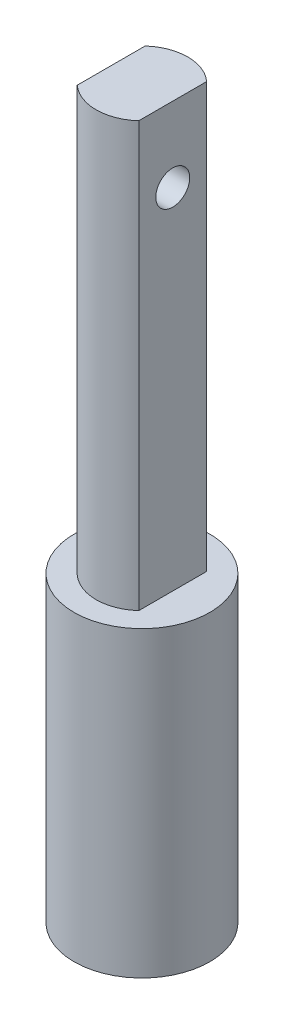
from build123d import *

# Parameters (mm, degrees)
SKETCH1_R           = 4
BOSS_EXTRUDE1_DEPTH = 9
SKETCH2_R           = 4
BOSS_EXTRUDE2_DEPTH = 8.83
BOSS_EXTRUDE3_DEPTH = 25
SKETCH4_R           = 1
CUT_EXTRUDE1_DEPTH  = 25


with BuildPart() as part:
    # Sketch1 → Boss-Extrude1 (new body)
    with BuildSketch(Plane(origin=(0, 0, 0), x_dir=(1, 0, 0), z_dir=(0, 1, 0))):
        Circle(SKETCH1_R)
        with BuildLine():
            Line((-2, 1.887458609), (2, 1.887458609))
            ThreePointArc((2, 1.887458609), (2.75, 0), (2, -1.887458609))
            Line((2, -1.887458609), (-2, -1.887458609))
            ThreePointArc((-2, -1.887458609), (-2.75, 0), (-2, 1.887458609))
        make_face(mode=Mode.SUBTRACT)
    extrude(amount=BOSS_EXTRUDE1_DEPTH)

    # Sketch2 → Boss-Extrude2 (add)
    with BuildSketch(Plane(origin=(0, 9, 0), x_dir=(1, 0, 0), z_dir=(0, 1, 0))):
        Circle(SKETCH2_R)
    extrude(amount=BOSS_EXTRUDE2_DEPTH)

    # Sketch3 → Boss-Extrude3 (add)
    with BuildSketch(Plane(origin=(0, 17.83, 0), x_dir=(1, 0, 0), z_dir=(0, 1, 0))):
        with BuildLine():
            Line((1.813835715, 2), (1.813835715, -2))
            ThreePointArc((1.813835715, -2), (0, -2.7), (-1.813835715, -2))
            Line((-1.813835715, -2), (-1.813835715, 2))
            ThreePointArc((-1.813835715, 2), (0, 2.7), (1.813835715, 2))
        make_face()
    extrude(amount=BOSS_EXTRUDE3_DEPTH)

    # Sketch4 → Cut-Extrude1 (cut)
    with BuildSketch(Plane(origin=(1.813835715, 0, 0), x_dir=(0, 0, -1), z_dir=(1, 0, 0))):
        with Locations((0, 38.421822436)):
            Circle(SKETCH4_R)
    extrude(amount=-CUT_EXTRUDE1_DEPTH, mode=Mode.SUBTRACT)


solid = part.part
